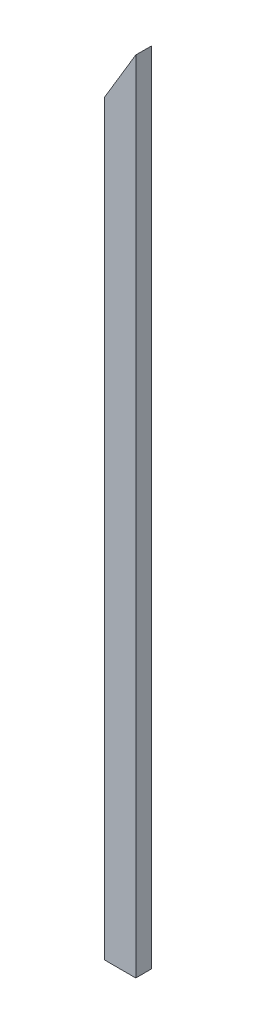
from build123d import *

# Parameters (mm, degrees)
SKETCH1_W           = 38.1
SKETCH1_H           = 980.4146
BOSS_EXTRUDE1_DEPTH = 19.05
CUT_EXTRUDE1_DEPTH  = 20.05


with BuildPart() as part:
    # Sketch1 → Boss-Extrude1 (new body)
    with BuildSketch(Plane.XY):
        with Locations((-275.968375076, -15.396581864)):
            Rectangle(SKETCH1_W, SKETCH1_H)
    extrude(amount=BOSS_EXTRUDE1_DEPTH)

    # Sketch2 → Cut-Extrude1 (cut, through all)
    with BuildSketch(Plane.XY.offset(19.05)):
        Polygon((-295.018375076, 411.15025702), (-256.918375076, 474.810718136), (-295.018375076, 474.810718136), align=None)
    extrude(amount=-CUT_EXTRUDE1_DEPTH, mode=Mode.SUBTRACT)


solid = part.part
